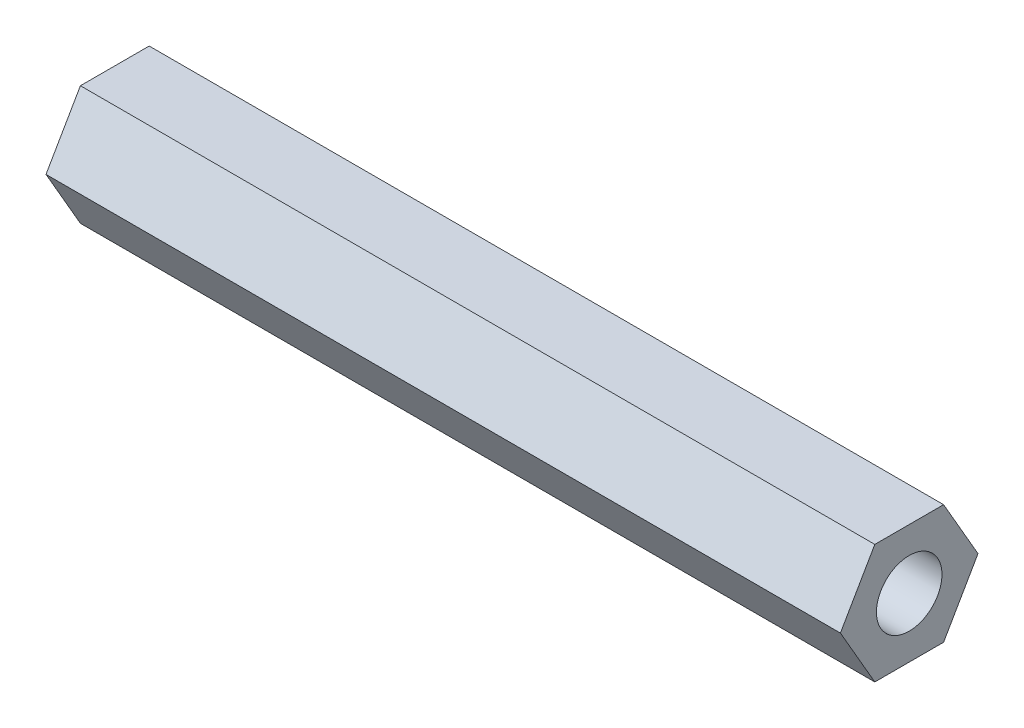
from build123d import *

# Parameters (mm, degrees)
EXTRUDE_1_DEPTH    = 40
HOLE_WIZARD_M4_1_D = 3.3


with BuildPart() as part:
    # 草图1 → 凸台-拉伸1 (new body)
    with BuildSketch(Plane(origin=(0, 0, 0), x_dir=(0, 0, -1), z_dir=(1, 0, 0))):
        Polygon((3.464101615, 0), (1.732050808, 3), (-1.732050808, 3), (-3.464101615, 0), (-1.732050808, -3), (1.732050808, -3), align=None)
    extrude(amount=EXTRUDE_1_DEPTH)

    # M4 螺纹孔1 (through all)
    with Locations(Plane.ZY):
        with Locations((0, 0)):
            Hole(HOLE_WIZARD_M4_1_D / 2)


solid = part.part
